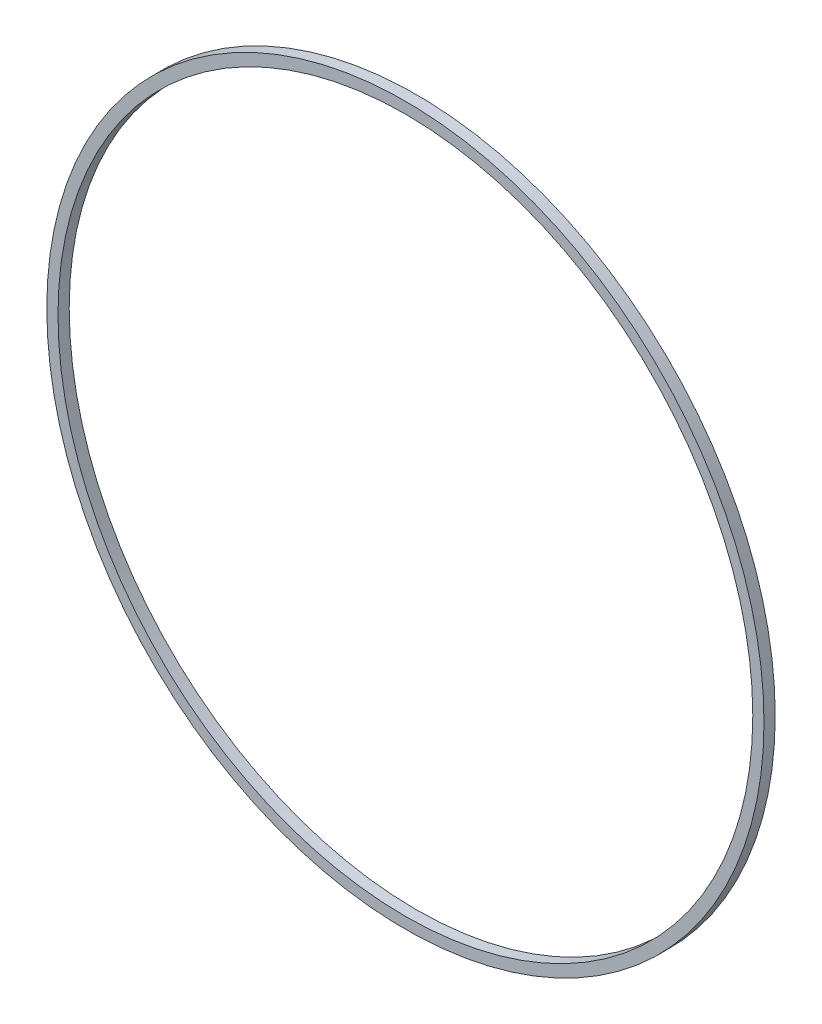
from build123d import *

# Parameters (mm, degrees)
SCHIZZO1_R                   = 16
SCHIZZO1_R_2                 = 15.5
ESTRUSIONE_ESTRUSIONE1_DEPTH = 0.5


with BuildPart() as part:
    # Schizzo1 → Estrusione-Estrusione1 (new body)
    with BuildSketch(Plane.XY):
        Circle(SCHIZZO1_R)
        Circle(SCHIZZO1_R_2, mode=Mode.SUBTRACT)
    extrude(amount=ESTRUSIONE_ESTRUSIONE1_DEPTH)


solid = part.part
